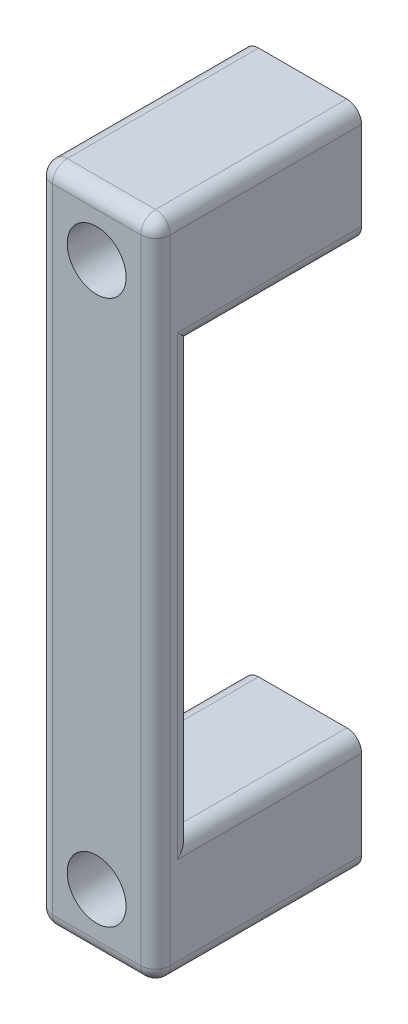
from build123d import *

# Parameters (mm, degrees)
SKETCH1_W           = 16
SKETCH1_H           = 90
SKETCH1_R           = 2.2
BOSS_EXTRUDE1_DEPTH = 28
SKETCH2_W           = 23
SKETCH2_H           = 58
CUT_EXTRUDE1_DEPTH  = 16
SKETCH3_R           = 4
CUT_EXTRUDE2_DEPTH  = 22
FILLET1_R           = 2


with BuildPart() as part:
    # Sketch1 → Boss-Extrude1 (new body)
    with BuildSketch(Plane.XY):
        with Locations((8, 45)):
            Rectangle(SKETCH1_W, SKETCH1_H)
        with Locations((8, 82)):
            Circle(SKETCH1_R, mode=Mode.SUBTRACT)
        with Locations((8, 8)):
            Circle(SKETCH1_R, mode=Mode.SUBTRACT)
    extrude(amount=BOSS_EXTRUDE1_DEPTH)

    # Sketch2 → Cut-Extrude1 (cut)
    with BuildSketch(Plane(origin=(16, 0, 0), x_dir=(0, 0, -1), z_dir=(1, 0, 0))):
        with Locations((-11.5, 45)):
            Rectangle(SKETCH2_W, SKETCH2_H)
    extrude(amount=-CUT_EXTRUDE1_DEPTH, mode=Mode.SUBTRACT)

    # Sketch3 → Cut-Extrude2 (cut)
    with BuildSketch(Plane.XY.offset(28)):
        with Locations((8, 82)):
            Circle(SKETCH3_R)
        with Locations((8, 8)):
            Circle(SKETCH3_R)
    extrude(amount=-CUT_EXTRUDE2_DEPTH, mode=Mode.SUBTRACT)

    # Fillet1
    fillet1_edges = [part.edges().sort_by_distance(p)[0] for p in [
        (16, 45, 28),
        (8, 90, 28),
        (16, 74, 11.5),
        (16, 45, 23),
        (16, 16, 11.5),
        (0, 16, 11.5),
        (0, 45, 23),
        (0, 74, 11.5),
        (0, 45, 28),
        (0, 90, 14),
        (16, 90, 14),
        (16, 0, 14),
        (0, 0, 14),
        (8, 0, 28),
    ]]
    fillet(fillet1_edges, radius=FILLET1_R)


solid = part.part
